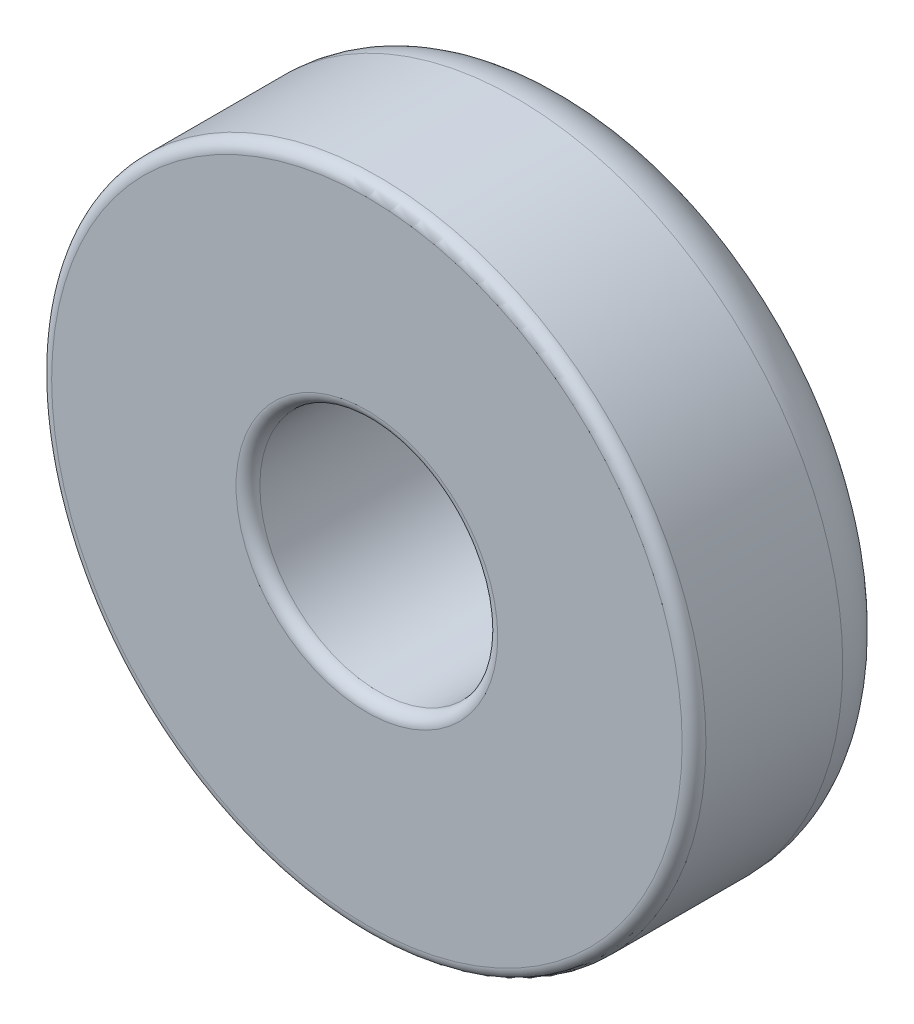
from build123d import *

# Parameters (mm, degrees)
SKETCH1_R           = 2.75
SKETCH1_R_2         = 1
EXTRUDE_THIN1_DEPTH = 1.75
FILLET1_R           = 0.5
FILLET2_R           = 0.1


with BuildPart() as part:
    # Sketch1 → Extrude-Thin1 (new body)
    with BuildSketch(Plane.XY):
        Circle(SKETCH1_R)
        Circle(SKETCH1_R_2, mode=Mode.SUBTRACT)
    extrude(amount=EXTRUDE_THIN1_DEPTH)

    # Fillet1
    fillet1_edges = [part.edges().sort_by_distance(p)[0] for p in [
        (-2.75, 0, 0),
    ]]
    fillet(fillet1_edges, radius=FILLET1_R)

    # Fillet2
    fillet2_edges = [part.edges().sort_by_distance(p)[0] for p in [
        (-1, 0, 0),
        (-2.75, 0, 1.75),
        (-1, 0, 1.75),
    ]]
    fillet(fillet2_edges, radius=FILLET2_R)


solid = part.part
